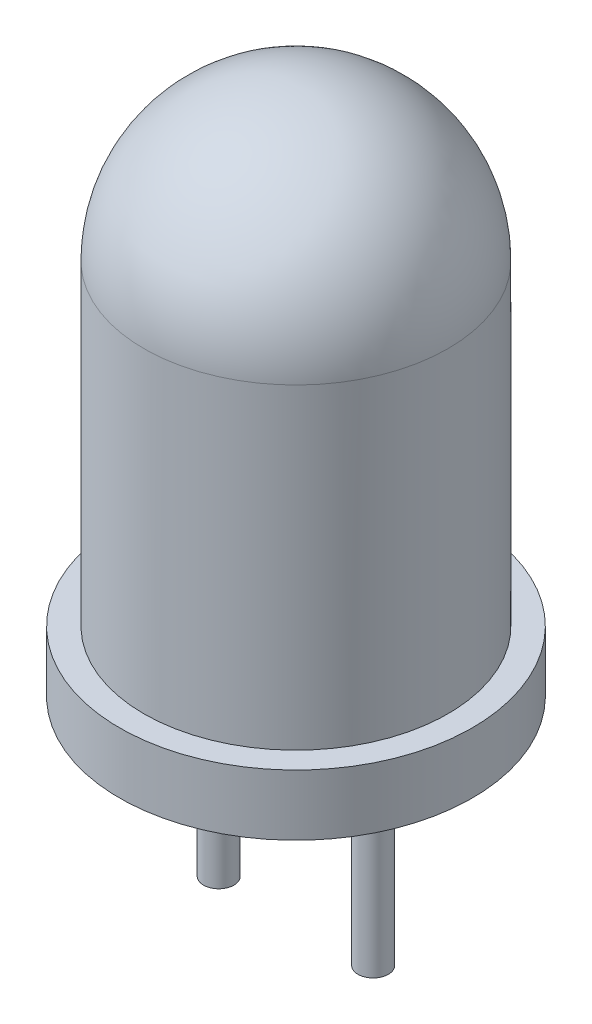
from build123d import *

# Parameters (mm, degrees)
SKETCH3_R           = 0.25
BOSS_EXTRUDE2_DEPTH = 3.2


with BuildPart() as part:
    # Sketch2 → Revolve1 (revolve)
    with BuildSketch(Plane.XY):
        with BuildLine():
            Line((2.5, 6.2), (2.5, 1))
            Line((2.5, 1), (2.9, 1))
            Line((2.9, 1), (2.9, 0))
            Line((2.9, 0), (0, 0))
            Line((0, 0), (0, 8.7))
            ThreePointArc((0, 8.7), (1.767766953, 7.967766953), (2.5, 6.2))
        make_face()
    revolve(axis=Axis((0, 0, 0), (0, 1, 0)))

    # Sketch3 → Boss-Extrude2 (add)
    with BuildSketch(Plane(origin=(0, 0, 0), x_dir=(1, 0, 0), z_dir=(0, 1, 0))):
        with Locations((-1.27, 0)):
            Circle(SKETCH3_R)
        with Locations((1.27, 0)):
            Circle(SKETCH3_R)
    extrude(amount=-BOSS_EXTRUDE2_DEPTH)


solid = part.part
